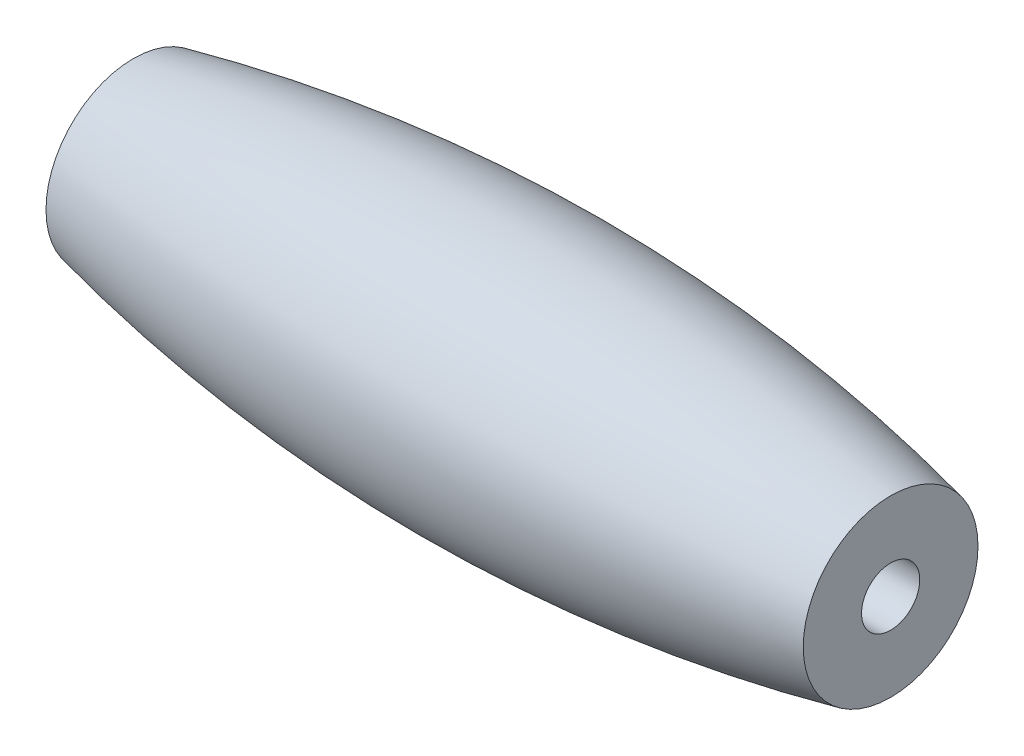
from build123d import *

# Parameters (mm, degrees)
SKETCH8_R               = 0.5
CUT_EXTRUDE1_DEPTH      = 7.5000001
CUT_EXTRUDE1_DEPTH_BACK = 7.5000001


with BuildPart() as part:
    # Sketch4 → Revolve1 (revolve)
    with BuildSketch(Plane.XY):
        with BuildLine():
            Line((-6.5, 0), (-6.5, 1.5))
            ThreePointArc((-6.5, 1.5), (0, 2.212630709), (6.5, 1.5))
            Line((6.5, 1.5), (6.5, 0))
            Line((6.5, 0), (-6.5, 0))
        make_face()
    revolve(axis=Axis((0, 0, 0), (1, 0, 0)))

    # Sketch8 → Cut-Extrude1 (cut, two sides)
    with BuildSketch(Plane(origin=(0, 0, 0), x_dir=(0, 0, -1), z_dir=(1, 0, 0))) as cut_extrude1_sk:
        Circle(SKETCH8_R)
    extrude(amount=CUT_EXTRUDE1_DEPTH, mode=Mode.SUBTRACT)
    extrude(cut_extrude1_sk.sketch, amount=-CUT_EXTRUDE1_DEPTH_BACK, mode=Mode.SUBTRACT)


solid = part.part
